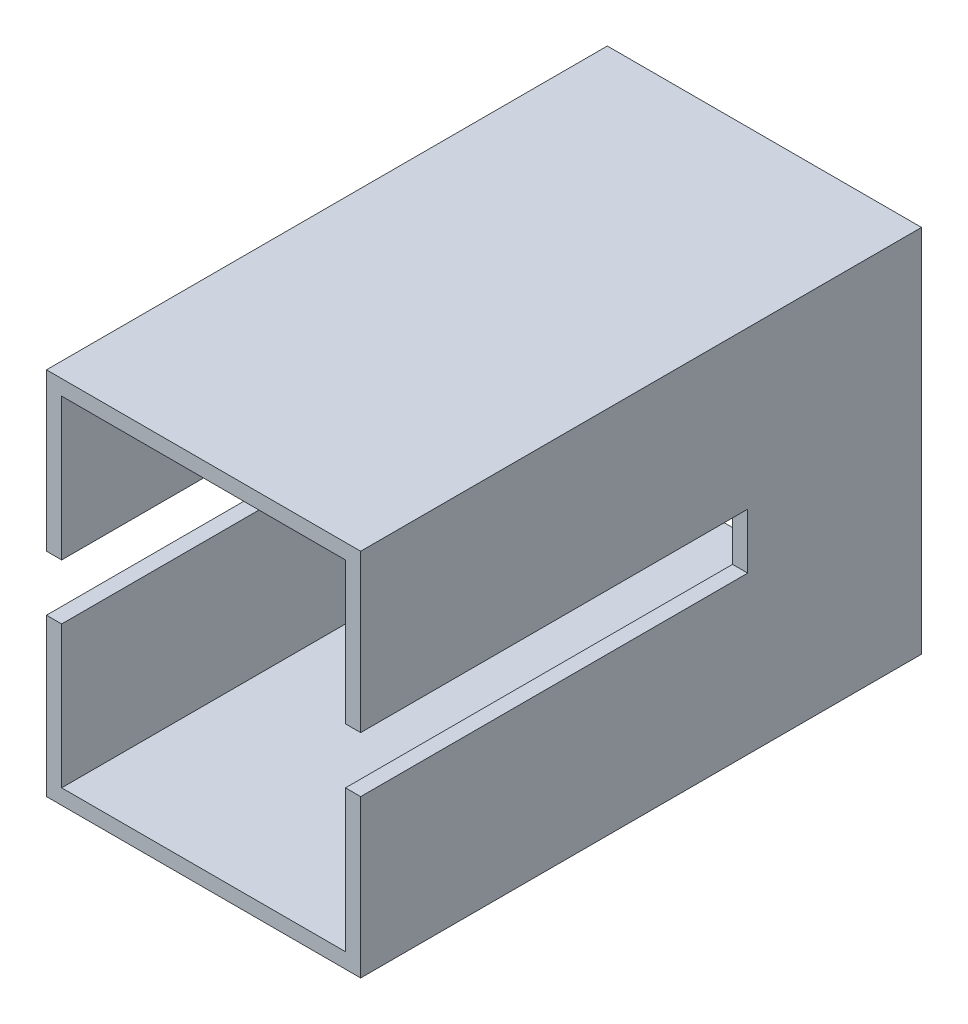
from build123d import *

# Parameters (mm, degrees)
SKETCH3_W           = 20.7
SKETCH3_H           = 24.35
SKETCH3_W_2         = 18.7
SKETCH3_H_2         = 22.35
EXTRUDE_THIN1_DEPTH = 36.95
SKETCH4_W           = 25.5
SKETCH4_H           = 3.65
CUT_EXTRUDE1_DEPTH  = 21.7


with BuildPart() as part:
    # Sketch3 → Extrude-Thin1 (new body)
    with BuildSketch(Plane.XY):
        Rectangle(SKETCH3_W, SKETCH3_H)
        Rectangle(SKETCH3_W_2, SKETCH3_H_2, mode=Mode.SUBTRACT)
    extrude(amount=EXTRUDE_THIN1_DEPTH)

    # Sketch4 → Cut-Extrude1 (cut, through all)
    with BuildSketch(Plane.ZY.offset(10.35)):
        with Locations((24.2, 0)):
            Rectangle(SKETCH4_W, SKETCH4_H)
    extrude(amount=-CUT_EXTRUDE1_DEPTH, mode=Mode.SUBTRACT)


solid = part.part
